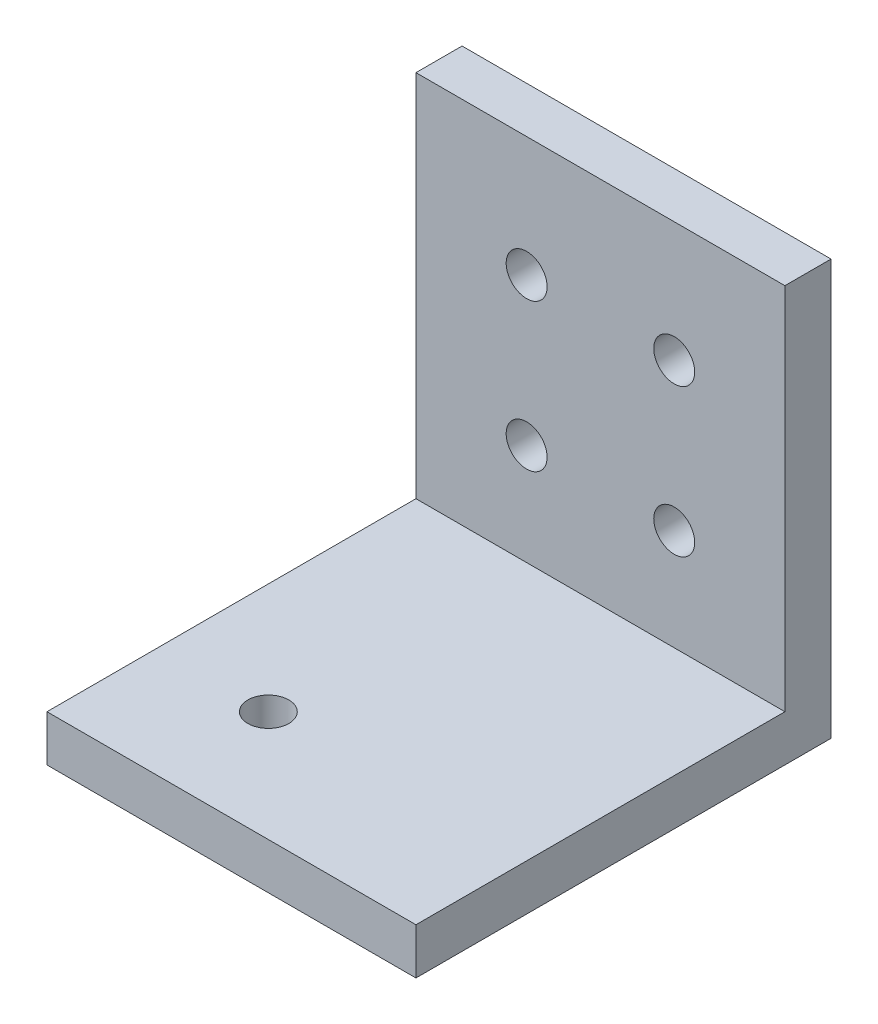
from build123d import *

# Parameters (mm, degrees)
SKETCH1_W            = 25.4
SKETCH1_H            = 28.575
BOSS_EXTRUDE1_DEPTH  = 3.175
SKETCH2_W            = 25.4
SKETCH2_H            = 3.175
BOSS_EXTRUDE2_DEPTH  = 25.4
SKETCH4_R            = 1.4097
CUT_EXTRUDE1_DEPTH   = 29.575
LPATTERN1_COUNT      = 2
LPATTERN1_PITCH      = 10.16
LPATTERN1_COUNT_DIR2 = 2
LPATTERN1_PITCH_DIR2 = 10.16
SKETCH5_R            = 1.4097
CUT_EXTRUDE2_DEPTH   = 4.175


with BuildPart() as part:
    # Sketch1 → Boss-Extrude1 (new body)
    with BuildSketch(Plane.XY):
        Rectangle(SKETCH1_W, SKETCH1_H)
    extrude(amount=BOSS_EXTRUDE1_DEPTH)

    # Sketch2 → Boss-Extrude2 (add)
    with BuildSketch(Plane.XY.offset(3.175)):
        with Locations((0, -12.7)):
            Rectangle(SKETCH2_W, SKETCH2_H)
    extrude(amount=BOSS_EXTRUDE2_DEPTH)

    # Sketch4 → Cut-Extrude1 (cut, through all)
    with BuildSketch(Plane(origin=(0, 0, 0), x_dir=(-1, 0, 0), z_dir=(0, 0, -1))):
        with Locations((-5.08, 6.0325)):
            Circle(SKETCH4_R)
    cut_extrude1 = extrude(amount=-CUT_EXTRUDE1_DEPTH, mode=Mode.SUBTRACT)

    # LPattern1: Cut-Extrude1 2 × 2
    with Locations(*[(-j * LPATTERN1_PITCH_DIR2, -i * LPATTERN1_PITCH, 0) for i in range(LPATTERN1_COUNT) for j in range(LPATTERN1_COUNT_DIR2) if (i, j) != (0, 0)]):
        add(cut_extrude1, mode=Mode.SUBTRACT)

    # Sketch5 → Cut-Extrude2 (cut, through all)
    with BuildSketch(Plane(origin=(0, -11.1125, 0), x_dir=(1, 0, 0), z_dir=(0, 1, 0))):
        with Locations((-5.08, -20.955)):
            Circle(SKETCH5_R)
    extrude(amount=-CUT_EXTRUDE2_DEPTH, mode=Mode.SUBTRACT)


solid = part.part
